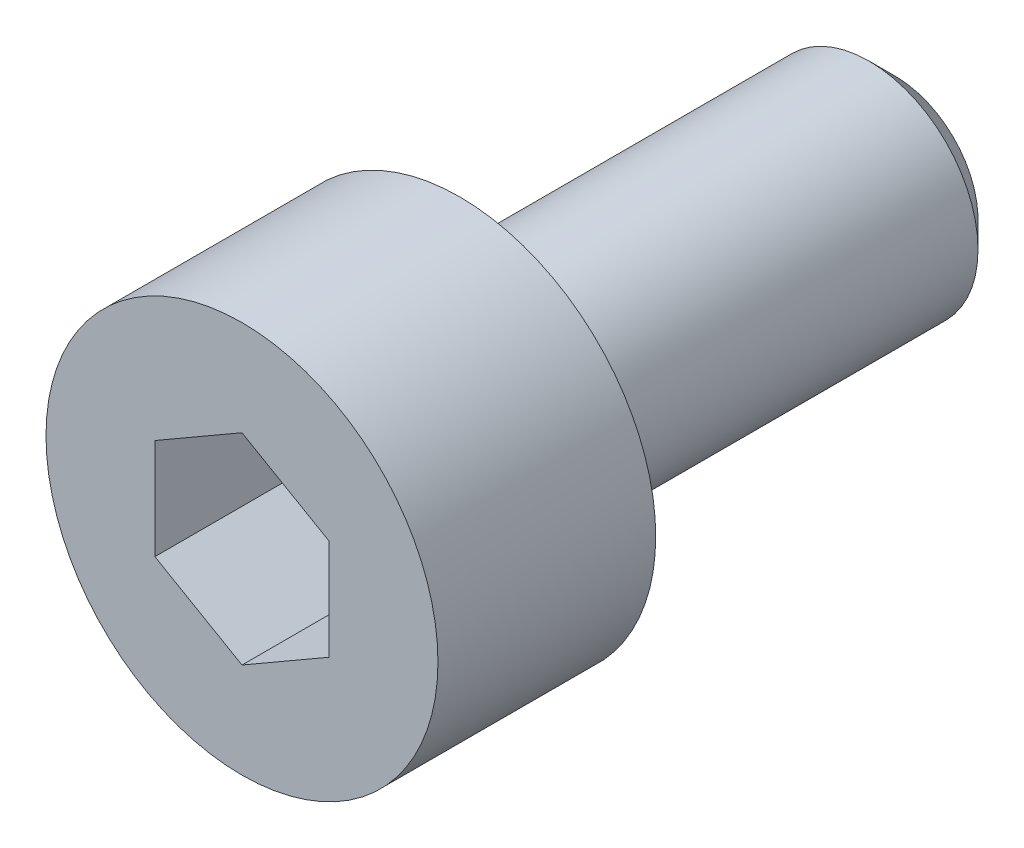
from build123d import *

# Parameters (mm, degrees)
SKETCH1_R           = 2.25
BOSS_EXTRUDE1_DEPTH = 2.5
SKETCH2_R           = 1.25
BOSS_EXTRUDE2_DEPTH = 5
CHAMFER1_SIZE       = 0.3
CUT_EXTRUDE1_DEPTH  = 2


with BuildPart() as part:
    # Sketch1 → Boss-Extrude1 (new body)
    with BuildSketch(Plane.XY):
        Circle(SKETCH1_R)
    extrude(amount=BOSS_EXTRUDE1_DEPTH)

    # Sketch2 → Boss-Extrude2 (add)
    with BuildSketch(Plane(origin=(0, 0, 0), x_dir=(-1, 0, 0), z_dir=(0, 0, -1))):
        Circle(SKETCH2_R)
    extrude(amount=BOSS_EXTRUDE2_DEPTH)

    # Chamfer1
    chamfer1_edges = [part.edges().sort_by_distance(p)[0] for p in [
        (1.25, 0, -5),
    ]]
    chamfer(chamfer1_edges, length=CHAMFER1_SIZE)

    # Sketch3 → Cut-Extrude1 (cut)
    with BuildSketch(Plane.XY.offset(2.5)):
        Polygon((0, 1.154700538), (-1, 0.577350269), (-1, -0.577350269), (0, -1.154700538), (1, -0.577350269), (1, 0.577350269), align=None)
    extrude(amount=-CUT_EXTRUDE1_DEPTH, mode=Mode.SUBTRACT)


solid = part.part
